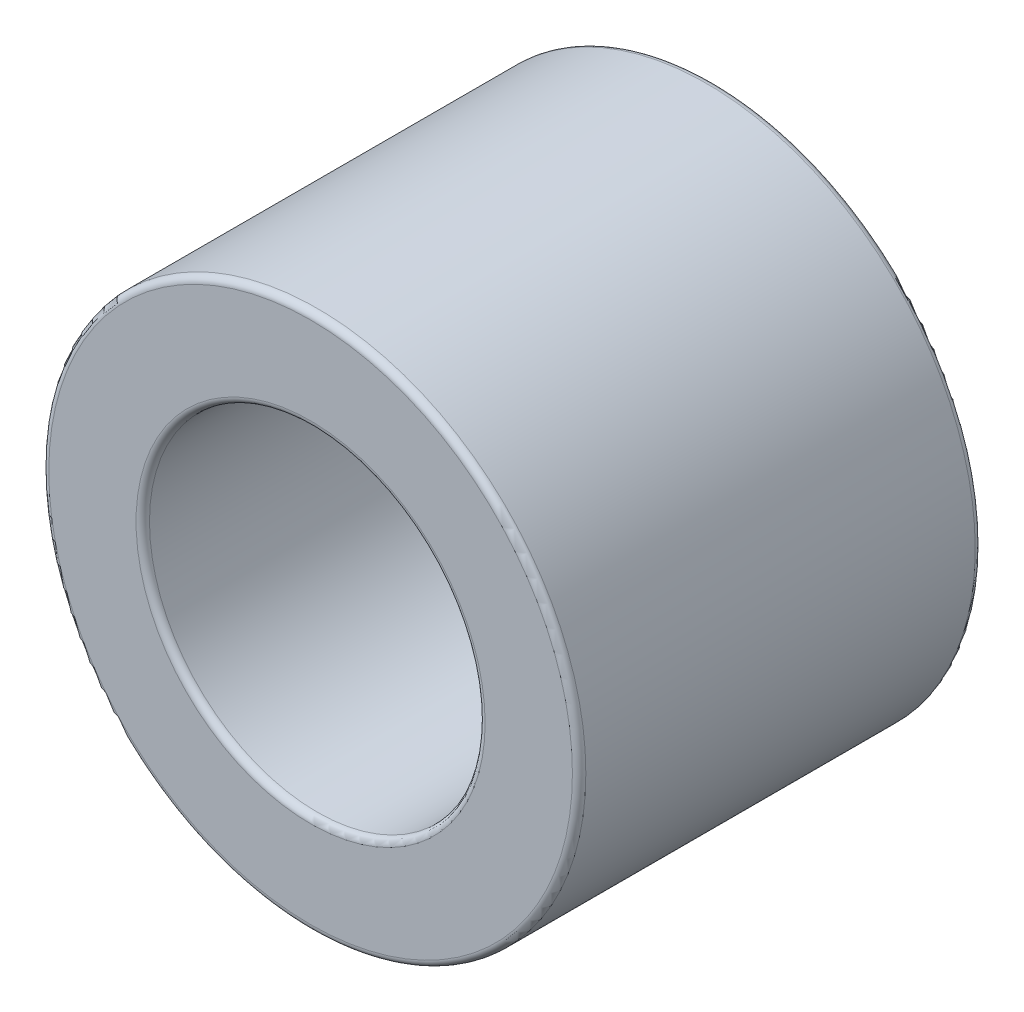
from build123d import *

# Parameters (mm, degrees)
SKETCH1_R           = 4
SKETCH1_R_2         = 2.5
BOSS_EXTRUDE1_DEPTH = 6
FILLET1_R           = 0.1


with BuildPart() as part:
    # Sketch1 → Boss-Extrude1 (new body)
    with BuildSketch(Plane.XY):
        Circle(SKETCH1_R)
        Circle(SKETCH1_R_2, mode=Mode.SUBTRACT)
    extrude(amount=BOSS_EXTRUDE1_DEPTH)

    # Fillet1
    fillet1_edges = [part.edges().sort_by_distance(p)[0] for p in [
        (-4, 0, 0),
        (-4, 0, 6),
        (-2.5, 0, 0),
        (-2.5, 0, 6),
    ]]
    fillet(fillet1_edges, radius=FILLET1_R)


solid = part.part
